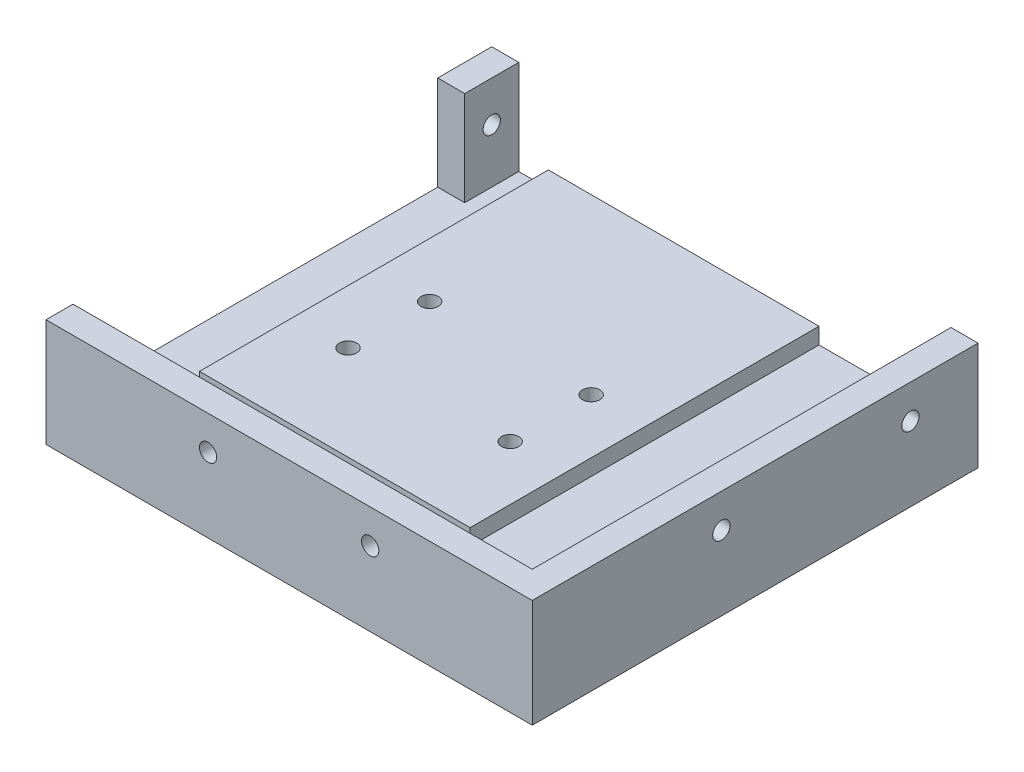
from build123d import *

# Parameters (mm, degrees)
SKETCH1_W           = 90
SKETCH1_H           = 75
BOSS_EXTRUDE1_DEPTH = 5
SKETCH2_W           = 90
SKETCH2_H           = 5
BOSS_EXTRUDE2_DEPTH = 15
SKETCH3_W           = 5
SKETCH3_H           = 15
BOSS_EXTRUDE3_DEPTH = 70
CUT_EXTRUDE1_REACH  = 92
SKETCH5_R           = 1.6
CUT_EXTRUDE3_REACH  = 77
SKETCH7_R           = 1.6
SKETCH8_W           = 50.1
SKETCH8_H           = 57.079275331
BOSS_EXTRUDE6_DEPTH = 3
CUT_EXTRUDE4_REACH  = 10
SKETCH9_R           = 1.6
CUT_EXTRUDE5_START  = -2.5
CUT_EXTRUDE5_DEPTH  = 2.5
BOSS_EXTRUDE7_DEPTH = 7.5
SKETCH12_W          = 5
SKETCH12_H          = 10
BOSS_EXTRUDE8_DEPTH = 17.5
CUT_EXTRUDE6_REACH  = 92
SKETCH13_R          = 1.6


with BuildPart() as part:
    # Sketch1 → Boss-Extrude1 (new body)
    with BuildSketch(Plane(origin=(0, 0, 0), x_dir=(1, 0, 0), z_dir=(0, 1, 0))):
        Rectangle(SKETCH1_W, SKETCH1_H)
    extrude(amount=BOSS_EXTRUDE1_DEPTH)

    # Sketch2 → Boss-Extrude2 (add)
    with BuildSketch(Plane(origin=(0, 5, 0), x_dir=(1, 0, 0), z_dir=(0, 1, 0))):
        with Locations((0, -35)):
            Rectangle(SKETCH2_W, SKETCH2_H)
    extrude(amount=BOSS_EXTRUDE2_DEPTH)

    # Sketch3 → Boss-Extrude3 (add)
    with BuildSketch(Plane(origin=(0, 0, 32.5), x_dir=(-1, 0, 0), z_dir=(0, 0, -1))):
        with Locations((-42.5, 12.5)):
            Rectangle(SKETCH3_W, SKETCH3_H)
    extrude(amount=BOSS_EXTRUDE3_DEPTH)

    # Sketch5 → Cut-Extrude1 (cut, up to next)
    with BuildSketch(Plane(origin=(45, 0, 0), x_dir=(0, 0, -1), z_dir=(1, 0, 0)), mode=Mode.PRIVATE) as cut_extrude1_sk1:
        with Locations((-2.5, 13.75)):
            Circle(SKETCH5_R)
    cut_extrude1_tool1 = extrude(cut_extrude1_sk1.sketch, amount=-CUT_EXTRUDE1_REACH, mode=Mode.PRIVATE) & part.part
    add(cut_extrude1_tool1.solids().sort_by_distance((45, 13.75, 2.5))[0], mode=Mode.SUBTRACT)
    # Sketch5 → Cut-Extrude1 (cut, up to next)
    with BuildSketch(Plane(origin=(45, 0, 0), x_dir=(0, 0, -1), z_dir=(1, 0, 0)), mode=Mode.PRIVATE) as cut_extrude1_sk2:
        with Locations((32.5, 13.75)):
            Circle(SKETCH5_R)
    cut_extrude1_tool2 = extrude(cut_extrude1_sk2.sketch, amount=-CUT_EXTRUDE1_REACH, mode=Mode.PRIVATE) & part.part
    add(cut_extrude1_tool2.solids().sort_by_distance((45, 13.75, -32.5))[0], mode=Mode.SUBTRACT)

    # Sketch7 → Cut-Extrude3 (cut, up to next)
    with BuildSketch(Plane.XY.offset(37.5), mode=Mode.PRIVATE) as cut_extrude3_sk1:
        with Locations((-15, 13.75)):
            Circle(SKETCH7_R)
    cut_extrude3_tool1 = extrude(cut_extrude3_sk1.sketch, amount=-CUT_EXTRUDE3_REACH, mode=Mode.PRIVATE) & part.part
    add(cut_extrude3_tool1.solids().sort_by_distance((-15, 13.75, 37.5))[0], mode=Mode.SUBTRACT)
    # Sketch7 → Cut-Extrude3 (cut, up to next)
    with BuildSketch(Plane.XY.offset(37.5), mode=Mode.PRIVATE) as cut_extrude3_sk2:
        with Locations((15, 13.75)):
            Circle(SKETCH7_R)
    cut_extrude3_tool2 = extrude(cut_extrude3_sk2.sketch, amount=-CUT_EXTRUDE3_REACH, mode=Mode.PRIVATE) & part.part
    add(cut_extrude3_tool2.solids().sort_by_distance((15, 13.75, 37.5))[0], mode=Mode.SUBTRACT)

    # Sketch8 → Boss-Extrude6 (add)
    with BuildSketch(Plane(origin=(0, 5, 0), x_dir=(1, 0, 0), z_dir=(0, 1, 0))):
        with Locations((-9.469239884, 8.960362334)):
            Rectangle(SKETCH8_W, SKETCH8_H)
    extrude(amount=BOSS_EXTRUDE6_DEPTH)

    # Sketch9 → Cut-Extrude4 (cut, up to next)
    with BuildSketch(Plane(origin=(0, 8, 0), x_dir=(1, 0, 0), z_dir=(0, 1, 0)), mode=Mode.PRIVATE) as cut_extrude4_sk1:
        with Locations((-24.419239884, 12.920724669)):
            Circle(SKETCH9_R)
    cut_extrude4_tool1 = extrude(cut_extrude4_sk1.sketch, amount=-CUT_EXTRUDE4_REACH, mode=Mode.PRIVATE) & part.part
    add(cut_extrude4_tool1.solids().sort_by_distance((-24.41924, 8, -12.920725))[0], mode=Mode.SUBTRACT)
    # Sketch9 → Cut-Extrude4 (cut, up to next)
    with BuildSketch(Plane(origin=(0, 8, 0), x_dir=(1, 0, 0), z_dir=(0, 1, 0)), mode=Mode.PRIVATE) as cut_extrude4_sk2:
        with Locations((5.480760116, 12.920724669)):
            Circle(SKETCH9_R)
    cut_extrude4_tool2 = extrude(cut_extrude4_sk2.sketch, amount=-CUT_EXTRUDE4_REACH, mode=Mode.PRIVATE) & part.part
    add(cut_extrude4_tool2.solids().sort_by_distance((5.48076, 8, -12.920725))[0], mode=Mode.SUBTRACT)
    # Sketch9 → Cut-Extrude4 (cut, up to next)
    with BuildSketch(Plane(origin=(0, 8, 0), x_dir=(1, 0, 0), z_dir=(0, 1, 0)), mode=Mode.PRIVATE) as cut_extrude4_sk3:
        with Locations((5.480760116, -2.079275331)):
            Circle(SKETCH9_R)
    cut_extrude4_tool3 = extrude(cut_extrude4_sk3.sketch, amount=-CUT_EXTRUDE4_REACH, mode=Mode.PRIVATE) & part.part
    add(cut_extrude4_tool3.solids().sort_by_distance((5.48076, 8, 2.079275))[0], mode=Mode.SUBTRACT)
    # Sketch9 → Cut-Extrude4 (cut, up to next)
    with BuildSketch(Plane(origin=(0, 8, 0), x_dir=(1, 0, 0), z_dir=(0, 1, 0)), mode=Mode.PRIVATE) as cut_extrude4_sk4:
        with Locations((-24.519239884, -2.079275331)):
            Circle(SKETCH9_R)
    cut_extrude4_tool4 = extrude(cut_extrude4_sk4.sketch, amount=-CUT_EXTRUDE4_REACH, mode=Mode.PRIVATE) & part.part
    add(cut_extrude4_tool4.solids().sort_by_distance((-24.51924, 8, 2.079275))[0], mode=Mode.SUBTRACT)

    # Sketch10 → Cut-Extrude5 (cut)
    with BuildSketch(Plane(origin=(0, 8, 0), x_dir=(1, 0, 0), z_dir=(0, 1, 0)).offset(CUT_EXTRUDE5_START)):
        Polygon((-21.091380421, -2.304248294), (-22.61047785, 0.776851563), (-26.038337313, 1.001824527), (-27.947099347, -1.854302367), (-26.428001917, -4.935402224), (-23.000142454, -5.160375188), align=None)
        Polygon((8.908619579, -2.304248294), (7.38952215, 0.776851563), (3.961662687, 1.001824527), (2.052900653, -1.854302367), (3.571998083, -4.935402224), (6.999857546, -5.160375188), align=None)
        Polygon((8.908619579, 12.695751706), (7.38952215, 15.776851563), (3.961662687, 16.001824527), (2.052900653, 13.145697633), (3.571998083, 10.064597776), (6.999857546, 9.839624812), align=None)
        Polygon((-20.991380369, 12.695752494), (-22.510478507, 15.776852002), (-25.938338022, 16.001824178), (-27.847099399, 13.145696845), (-26.328001261, 10.064597337), (-22.900141746, 9.839625161), align=None)
    extrude(amount=-CUT_EXTRUDE5_DEPTH, mode=Mode.SUBTRACT)

    # Sketch11 → Boss-Extrude7 (add)
    with BuildSketch(Plane(origin=(0, 0, -37.5), x_dir=(-1, 0, 0), z_dir=(0, 0, -1))):
        Polygon((-45, 20), (-45, 0), (45, 0), (45, 5), (34.519239884, 5), (34.519239884, 8), (-15.580760116, 8), (-15.580760116, 5), (-40, 5), (-40, 20), align=None)
    extrude(amount=BOSS_EXTRUDE7_DEPTH)

    # Sketch12 → Boss-Extrude8 (add)
    with BuildSketch(Plane(origin=(0, 5, 0), x_dir=(1, 0, 0), z_dir=(0, 1, 0))):
        with Locations((-42.5, 40)):
            Rectangle(SKETCH12_W, SKETCH12_H)
    extrude(amount=BOSS_EXTRUDE8_DEPTH)

    # Sketch13 → Cut-Extrude6 (cut, up to next)
    with BuildSketch(Plane.ZY.offset(45), mode=Mode.PRIVATE) as cut_extrude6_sk1:
        with Locations((-40, 15)):
            Circle(SKETCH13_R)
    cut_extrude6_tool1 = extrude(cut_extrude6_sk1.sketch, amount=-CUT_EXTRUDE6_REACH, mode=Mode.PRIVATE) & part.part
    add(cut_extrude6_tool1.solids().sort_by_distance((-45, 15, -40))[0], mode=Mode.SUBTRACT)


solid = part.part
